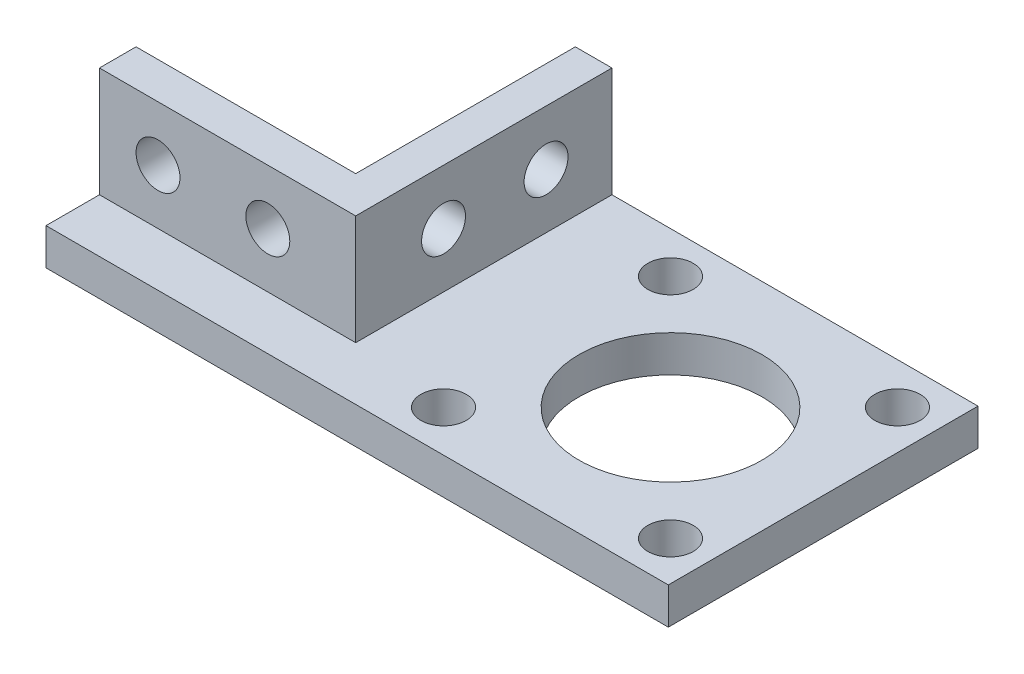
from build123d import *

# Parameters (mm, degrees)
ESBO_O1_W                = 35
ESBO_O1_H                = 20
RESSALTO_EXTRUS_O1_DEPTH = 5
ESBO_O2_W                = 5
ESBO_O2_H                = 20
RESSALTO_EXTRUS_O2_DEPTH = 30
ESBO_O4_W                = 42.3
ESBO_O4_H                = 5
RESSALTO_EXTRUS_O3_DEPTH = 50
ESBO_O5_W                = 7.3
ESBO_O5_H                = 5
RESSALTO_EXTRUS_O4_DEPTH = 35
ESBO_O6_R                = 3.1
ESBO_O6_R_2              = 12.5
CORTE_EXTRUS_O1_DEPTH    = 39
ESBO_O7_R                = 3
CORTE_EXTRUS_O2_DEPTH    = 36
ESBO_O8_R                = 3
CORTE_EXTRUS_O3_DEPTH    = 10


with BuildPart() as part:
    # Esboço1 → Ressalto-extrusão1 (new body)
    with BuildSketch(Plane.XY):
        with Locations((-76.705213928, -265)):
            Rectangle(ESBO_O1_W, ESBO_O1_H)
    extrude(amount=RESSALTO_EXTRUS_O1_DEPTH)

    # Esboço2 → Ressalto-extrusão2 (add)
    with BuildSketch(Plane(origin=(0, 0, 0), x_dir=(-1, 0, 0), z_dir=(0, 0, -1))):
        with Locations((61.705213928, -265)):
            Rectangle(ESBO_O2_W, ESBO_O2_H)
    extrude(amount=RESSALTO_EXTRUS_O2_DEPTH)

    # Esboço4 → Ressalto-extrusão3 (add)
    with BuildSketch(Plane(origin=(-59.205213928, 0, 0), x_dir=(0, 0, -1), z_dir=(1, 0, 0))):
        with Locations((8.85, -272.5)):
            Rectangle(ESBO_O4_W, ESBO_O4_H)
    extrude(amount=RESSALTO_EXTRUS_O3_DEPTH)

    # Esboço5 → Ressalto-extrusão4 (add)
    with BuildSketch(Plane.ZY.offset(59.205213928)):
        with Locations((8.65, -272.5)):
            Rectangle(ESBO_O5_W, ESBO_O5_H)
    extrude(amount=RESSALTO_EXTRUS_O4_DEPTH)

    # Esboço6 → Corte-extrusão1 (cut)
    with BuildSketch(Plane.XZ.offset(275)):
        with Locations((-14.555213928, 6.65)):
            Circle(ESBO_O6_R)
        with Locations((-45.555213928, -24.35)):
            Circle(ESBO_O6_R)
        with Locations((-30.055213928, -8.85)):
            Circle(ESBO_O6_R_2)
        with Locations((-45.555213928, 6.65)):
            Circle(ESBO_O6_R)
        with Locations((-14.555213928, -24.35)):
            Circle(ESBO_O6_R)
    extrude(amount=-CORTE_EXTRUS_O1_DEPTH, mode=Mode.SUBTRACT)

    # Esboço7 → Corte-extrusão2 (cut, through all)
    with BuildSketch(Plane(origin=(-59.205213928, 0, 0), x_dir=(0, 0, -1), z_dir=(1, 0, 0))):
        with Locations((21, -262.5)):
            Circle(ESBO_O7_R)
        with Locations((7, -262.5)):
            Circle(ESBO_O7_R)
    extrude(amount=-CORTE_EXTRUS_O2_DEPTH, mode=Mode.SUBTRACT)

    # Esboço8 → Corte-extrusão3 (cut)
    with BuildSketch(Plane.XY.offset(5)):
        with Locations((-71.205213928, -262.5)):
            Circle(ESBO_O8_R)
        with Locations((-86.205213928, -262.5)):
            Circle(ESBO_O8_R)
    extrude(amount=-CORTE_EXTRUS_O3_DEPTH, mode=Mode.SUBTRACT)


solid = part.part
